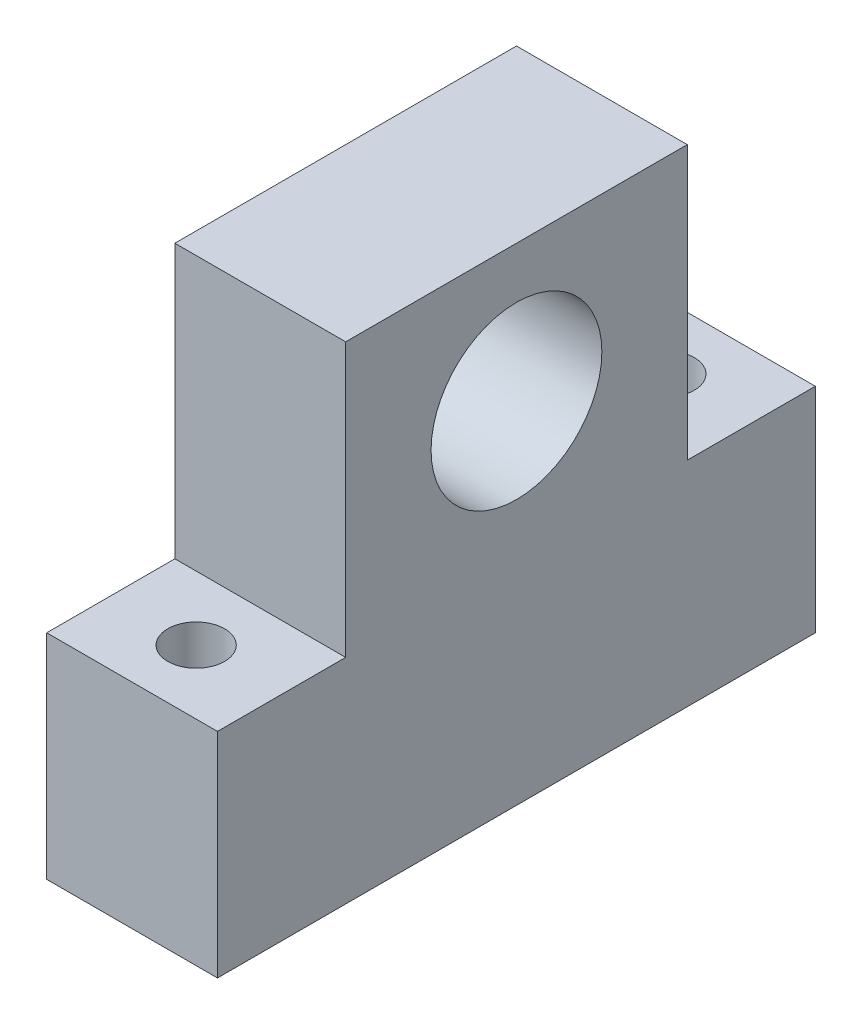
from build123d import *

# Parameters (mm, degrees)
SKETCH2_W           = 12.7
SKETCH2_H           = 44.45
BOSS_EXTRUDE1_DEPTH = 15.88
SKETCH4_W           = 12.7
SKETCH4_H           = 25.4
BOSS_EXTRUDE2_DEPTH = 20.32
SKETCH5_R           = 6.35
CUT_EXTRUDE1_DEPTH  = 12.7
SKETCH6_R           = 2.11
CUT_EXTRUDE2_DEPTH  = 20.7
SKETCH7_R           = 2.11
CUT_EXTRUDE3_DEPTH  = 16.7


with BuildPart() as part:
    # Sketch2 → Boss-Extrude1 (new body)
    with BuildSketch(Plane(origin=(0, 0, 0), x_dir=(1, 0, 0), z_dir=(0, 1, 0))):
        with Locations((6.35, 22.225)):
            Rectangle(SKETCH2_W, SKETCH2_H)
    extrude(amount=BOSS_EXTRUDE1_DEPTH)

    # Sketch4 → Boss-Extrude2 (add)
    with BuildSketch(Plane(origin=(0, 15.88, 0), x_dir=(1, 0, 0), z_dir=(0, 1, 0))):
        with Locations((6.35, 22.23)):
            Rectangle(SKETCH4_W, SKETCH4_H)
    extrude(amount=BOSS_EXTRUDE2_DEPTH)

    # Sketch5 → Cut-Extrude1 (cut)
    with BuildSketch(Plane(origin=(12.7, 0, 0), x_dir=(0, 0, -1), z_dir=(1, 0, 0))):
        with Locations((22.23, 26.04)):
            Circle(SKETCH5_R)
    extrude(amount=-CUT_EXTRUDE1_DEPTH, mode=Mode.SUBTRACT)

    # Sketch6 → Cut-Extrude2 (cut)
    with BuildSketch(Plane(origin=(0, 15.88, 0), x_dir=(1, 0, 0), z_dir=(0, 1, 0))):
        with Locations((6.35, 39.69)):
            Circle(SKETCH6_R)
    extrude(amount=-CUT_EXTRUDE2_DEPTH, mode=Mode.SUBTRACT)

    # Sketch7 → Cut-Extrude3 (cut)
    with BuildSketch(Plane(origin=(0, 15.88, 0), x_dir=(1, 0, 0), z_dir=(0, 1, 0))):
        with Locations((6.35, 4.765)):
            Circle(SKETCH7_R)
    extrude(amount=-CUT_EXTRUDE3_DEPTH, mode=Mode.SUBTRACT)


solid = part.part
